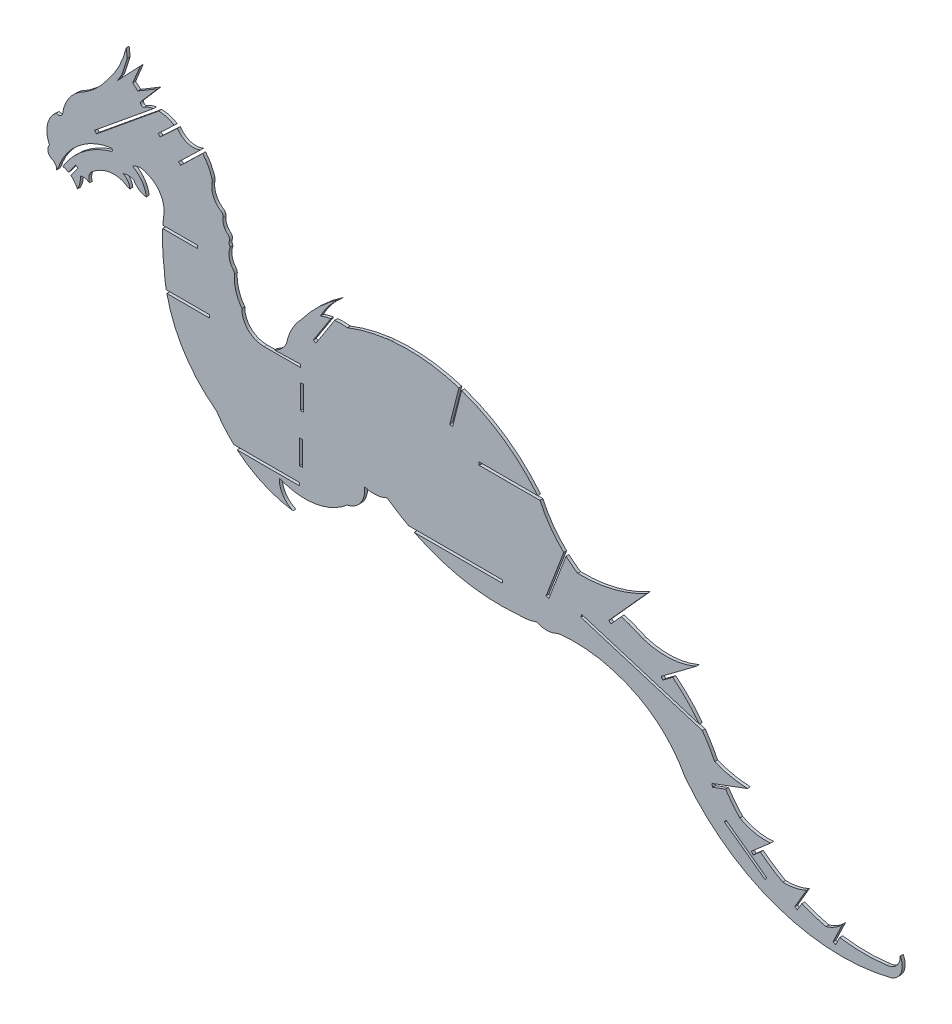
from build123d import *

# Parameters (mm, degrees)
BOSS_EXTRUDE1_DEPTH = 1.524
SKETCH2_W           = 25.4
SKETCH2_H           = 1.524
SKETCH2_W_2         = 19.05
CUT_EXTRUDE1_DEPTH  = 2.54
SKETCH3_W           = 35.680254641
SKETCH3_H           = 1.524
SKETCH3_W_2         = 1.524
SKETCH3_H_2         = 12.7
CUT_EXTRUDE2_DEPTH  = 1.524
SKETCH4_W           = 50.8
SKETCH4_H           = 1.524
SKETCH4_W_2         = 35.052
CUT_EXTRUDE3_DEPTH  = 2.54
CUT_EXTRUDE5_DEPTH  = 1.524
CUT_EXTRUDE6_DEPTH  = 1.524
BOSS_EXTRUDE3_DEPTH = 1.524
CUT_EXTRUDE11_DEPTH = 1.524
BOSS_EXTRUDE4_DEPTH = 1.524
CUT_EXTRUDE12_DEPTH = 1.524


with BuildPart() as part:
    # Sketch1 → Boss-Extrude1 (new body)
    with BuildSketch(Plane.XY):
        with BuildLine():
            Line((85.912962029, 218.976322287), (74.364894782, 207.800178371))
            Line((74.364894782, 207.800178371), (73.305043391, 208.895299839))
            Line((73.305043391, 208.895299839), (84.853110639, 220.071443755))
            ThreePointArc((84.853110639, 220.071443755), (78.049012426, 219.65544272), (72.670585697, 223.843680447))
            Line((72.670585697, 223.843680447), (63.510094231, 215.259742184))
            Line((63.510094231, 215.259742184), (62.468027874, 216.371800504))
            Line((62.468027874, 216.371800504), (70.942382834, 224.312787084))
            ThreePointArc((70.942382834, 224.312787084), (67.054478394, 226.098413751), (62.823075062, 226.730465466))
            Line((62.823075062, 226.730465466), (30.142398076, 199.999148642))
            Line((30.142398076, 199.999148642), (29.177504103, 201.1787908))
            Line((29.177504103, 201.1787908), (60.150273669, 226.513116541))
            ThreePointArc((60.150273669, 226.513116541), (57.805138379, 225.916638037), (55.584300985, 224.955738767))
            ThreePointArc((55.584300985, 224.955738767), (53.828520501, 224.627614987), (53.500396721, 226.383395471))
            Line((53.500396721, 226.383395471), (62.33783624, 236.627383356))
            Line((62.33783624, 236.627383356), (51.851124916, 230.366051046))
            Line((51.851124916, 230.366051046), (49.151424696, 232.695069558))
            Line((49.151424696, 232.695069558), (53.185497864, 242.40707472))
            Line((53.185497864, 242.40707472), (41.025224337, 229.643589626))
            Line((41.025224337, 229.643589626), (43.433429072, 233.496717201))
            Line((43.433429072, 233.496717201), (46.263069635, 242.40707472))
            Line((46.263069635, 242.40707472), (45.781428688, 247.042868834))
            ThreePointArc((45.781428688, 247.042868834), (41.995971337, 236.721956315), (35.94896473, 227.541290016))
            ThreePointArc((35.94896473, 227.541290016), (29.09512804, 219.879503048), (20.624117927, 214.055411308))
            ThreePointArc((20.624117927, 214.055411308), (15.224338721, 208.293396913), (12.411195321, 200.914735139))
            ThreePointArc((12.411195321, 200.914735139), (11.297888366, 198.952099018), (9.042009257, 198.90308507))
            ThreePointArc((9.042009257, 198.90308507), (4.33814825, 191.400740697), (5.45510478, 182.616442913))
            ThreePointArc((5.45510478, 182.616442913), (4.699658099, 179.178862984), (7.076072101, 176.582651909))
            ThreePointArc((7.076072101, 176.582651909), (8.681928736, 175.178852582), (9.155919385, 173.099246623))
            ThreePointArc((9.155919385, 173.099246623), (10.148365214, 174.754528749), (10.767132823, 176.582651909))
            ThreePointArc((10.767132823, 176.582651909), (21.457350988, 190.479061772), (37.540384678, 197.459534453))
            ThreePointArc((37.540384678, 197.459534453), (38.399050845, 197.023742181), (38.253676936, 196.07185515))
            ThreePointArc((38.253676936, 196.07185515), (23.454281696, 188.664818748), (12.411195666, 176.338564706))
            ThreePointArc((12.411195666, 176.338564706), (13.946155462, 175.867866548), (15.395234081, 175.17661443))
            Line((15.395234081, 175.17661443), (19.193185011, 180.368170906))
            Line((19.193185011, 180.368170906), (20.423183782, 179.468349244))
            Line((20.423183782, 179.468349244), (16.663613942, 174.329257269))
            ThreePointArc((16.663613942, 174.329257269), (18.661000235, 172.314724822), (20.070332405, 169.852677743))
            ThreePointArc((20.070332405, 169.852677743), (21.365371433, 173.099246623), (21.653855738, 176.582651909))
            ThreePointArc((21.653855738, 176.582651909), (24.130479455, 176.813374901), (26.404425737, 175.805373687))
            ThreePointArc((26.404425737, 175.805373687), (26.140099905, 178.575641373), (27.29048389, 181.109584523))
            ThreePointArc((27.29048389, 181.109584523), (31.315657742, 184.02733751), (35.94896473, 185.82949549))
            ThreePointArc((35.94896473, 185.82949549), (40.296382795, 186.180486334), (44.528814972, 185.127036633))
            ThreePointArc((44.528814972, 185.127036633), (46.050081316, 184.293182888), (47.664652975, 183.658579301))
            ThreePointArc((47.664652975, 183.658579301), (46.617864327, 186.759437448), (44.132482548, 188.888748401))
            ThreePointArc((44.132482548, 188.888748401), (46.927378665, 189.401991738), (49.720127416, 188.877189446))
            ThreePointArc((49.720127416, 188.877189446), (52.430877495, 185.78899139), (56.264556266, 184.309788796))
            ThreePointArc((56.264556266, 184.309788796), (54.005832171, 190.404410257), (49.151424692, 194.726559411))
            ThreePointArc((49.151424692, 194.726559411), (52.622637143, 196.071887584), (56.271469501, 195.333479703))
            ThreePointArc((56.271469501, 195.333479703), (63.140202409, 190.374955709), (65.667275166, 182.289143737))
            ThreePointArc((65.667275166, 182.289143737), (65.660634708, 182.146473197), (65.645985511, 182.004401456))
            ThreePointArc((65.645985511, 182.004401456), (65.308649849, 179.106572547), (65.05826469, 176.199939614))
            ThreePointArc((65.05826469, 176.199939614), (64.817716477, 170.23013431), (64.943690841, 164.25681285))
            ThreePointArc((64.943690841, 164.25681285), (65.248674161, 160.096824282), (65.731510792, 155.953710901))
            ThreePointArc((65.731510792, 155.953710901), (67.203599451, 145.391751604), (70.313958783, 135.191374453))
            ThreePointArc((70.313958783, 135.191374453), (71.821055501, 131.656935237), (73.525998925, 128.213569296))
            ThreePointArc((73.525998925, 128.213569296), (75.812647336, 124.2377173), (78.362926142, 120.425600032))
            ThreePointArc((78.362926142, 120.425600032), (82.189502592, 115.585453313), (86.440342726, 111.113310007))
            ThreePointArc((86.440342726, 111.113310007), (89.706771856, 108.17353201), (93.156824508, 105.451585897))
            ThreePointArc((93.156824508, 105.451585897), (110.528802987, 88.41476958), (133.395125801, 80.097917564))
            ThreePointArc((133.395125801, 80.097917564), (128.017180612, 84.692098497), (126.161809959, 91.517521021))
            ThreePointArc((126.161809959, 91.517521021), (144.825398714, 89.083026927), (161.902871554, 96.996068574))
            ThreePointArc((161.902871554, 96.996068574), (162.581404673, 97.150550573), (163.249151491, 97.3464742))
            ThreePointArc((163.249151491, 97.3464742), (169.387880456, 102.206558666), (170.898468081, 109.889171461))
            ThreePointArc((170.898468081, 109.889171461), (176.948552887, 109.130034546), (182.834138314, 110.723677912))
            ThreePointArc((182.834138314, 110.723677912), (215.501976144, 95.153256417), (251.553345423, 92.002950555))
            ThreePointArc((251.553345423, 92.002950555), (256.5263716, 92.287511732), (261.361002985, 93.486804767))
            ThreePointArc((261.361002985, 93.486804767), (265.661731663, 92.408703764), (270.068903721, 92.893887626))
            ThreePointArc((270.068903721, 92.893887626), (271.340370106, 93.345191698), (272.556022414, 93.930419519))
            ThreePointArc((272.556022414, 93.930419519), (294.27155938, 93.339542333), (314.820447647, 86.292779066))
            ThreePointArc((314.820447647, 86.292779066), (328.900505636, 75.991617879), (339.316129191, 61.996020689))
            ThreePointArc((339.316129191, 61.996020689), (388.035667666, 27.098915876), (447.920780712, 24.824143603))
            ThreePointArc((447.920780712, 24.824143603), (452.972758024, 29.895353293), (452.453481655, 37.03468061))
            ThreePointArc((452.453481655, 37.03468061), (450.48843079, 31.782753677), (445.425652694, 29.371853565))
            ThreePointArc((445.425652694, 29.371853565), (398.363856878, 35.971380344), (361.481703529, 65.939248862))
            ThreePointArc((361.481703529, 65.939248862), (358.230212062, 70.862760514), (355.313625064, 75.99176471))
            ThreePointArc((355.313625064, 75.99176471), (331.13682687, 105.472605001), (296.078527974, 120.457704058))
            ThreePointArc((296.078527974, 120.457704058), (295.802256425, 120.519391998), (295.534564817, 120.611438582))
            ThreePointArc((295.534564817, 120.611438582), (291.740578327, 122.096977041), (287.907209287, 123.477715902))
            ThreePointArc((287.907209287, 123.477715902), (287.71041735, 123.554861551), (287.520721146, 123.648102463))
            ThreePointArc((287.520721146, 123.648102463), (273.213478114, 134.730431911), (263.136393827, 149.76265069))
            ThreePointArc((263.136393827, 149.76265069), (228.535543485, 176.616937868), (185.253442578, 183.327476244))
            Line((185.253442578, 183.327476244), (169.728576525, 168.087659552))
            Line((169.728576525, 168.087659552), (168.660976375, 169.175228363))
            Line((168.660976375, 169.175228363), (182.792290548, 183.047079939))
            ThreePointArc((182.792290548, 183.047079939), (172.181721047, 181.012984757), (161.902904246, 177.686176451))
            ThreePointArc((161.902904246, 177.686176451), (158.600549933, 177.91649897), (155.293596172, 177.766002118))
            Line((155.293596172, 177.766002118), (145.35756693, 162.352041201))
            Line((145.35756693, 162.352041201), (144.076634601, 163.177745973))
            Line((144.076634601, 163.177745973), (153.302149625, 177.489471969))
            ThreePointArc((153.302149625, 177.489471969), (150.516535783, 176.859034352), (147.807142579, 175.955549696))
            ThreePointArc((147.807142579, 175.955549696), (152.400105667, 182.90469922), (158.253046613, 188.831677481))
            ThreePointArc((158.253046613, 188.831677481), (147.165486742, 179.923609241), (137.713521339, 169.29590894))
            ThreePointArc((137.713521339, 169.29590894), (132.746974171, 162.463425903), (129.978417774, 154.483168345))
            ThreePointArc((129.978417774, 154.483168345), (123.225134742, 148.241786274), (114.033790221, 147.957413737))
            ThreePointArc((114.033790221, 147.957413737), (108.511816279, 152.106071011), (106.529948644, 158.722395827))
            ThreePointArc((106.529948644, 158.722395827), (103.348649188, 165.164931098), (102.563630061, 172.30710667))
            ThreePointArc((102.563630061, 172.30710667), (102.437713886, 173.278490517), (101.953591078, 174.129998925))
            ThreePointArc((101.953591078, 174.129998925), (99.859339664, 178.593240513), (100.380158002, 183.495807466))
            ThreePointArc((100.380158002, 183.495807466), (99.850597988, 184.746376921), (99.941789819, 186.101383128))
            ThreePointArc((99.941789819, 186.101383128), (99.945959825, 187.594296625), (99.110677409, 188.831677481))
            ThreePointArc((99.110677409, 188.831677481), (97.032516131, 191.658219228), (96.620127494, 195.142186529))
            ThreePointArc((96.620127494, 195.142186529), (96.410256248, 196.563926462), (95.462412123, 197.644195824))
            ThreePointArc((95.462412123, 197.644195824), (91.490191499, 202.332428186), (90.909159352, 208.449654765))
            ThreePointArc((90.909159352, 208.449654765), (90.963307308, 209.060156595), (90.869641743, 209.66585557))
            ThreePointArc((90.869641743, 209.66585557), (88.893307621, 214.58834531), (85.912962029, 218.976322287))
        make_face()
    extrude(amount=BOSS_EXTRUDE1_DEPTH)

    # Sketch2 → Cut-Extrude1 (cut)
    with BuildSketch(Plane.XY.offset(1.524)):
        with Locations((76.728418917, 146.642575386)):
            Rectangle(SKETCH2_W, SKETCH2_H)
        with Locations((73.553418917, 175.110998199)):
            Rectangle(SKETCH2_W_2, SKETCH2_H)
    extrude(amount=-CUT_EXTRUDE1_DEPTH, mode=Mode.SUBTRACT)

    # Sketch3 → Cut-Extrude2 (cut)
    with BuildSketch(Plane.XY.offset(1.524)):
        Polygon((118.248884428, 147.262863837), (137.298884428, 147.262863837), (137.298884428, 148.786863837), (118.248884428, 148.241786274), align=None)
        with Locations((119.065368354, 93.929486967)):
            Rectangle(SKETCH3_W, SKETCH3_H)
        with Locations((138.060884428, 134.043246422)):
            Rectangle(SKETCH3_W_2, SKETCH3_H_2)
        with Locations((137.667495674, 108.668629124)):
            Rectangle(SKETCH3_W_2, SKETCH3_H_2)
    extrude(amount=-CUT_EXTRUDE2_DEPTH, mode=Mode.SUBTRACT)

    # Sketch4 → Cut-Extrude3 (cut)
    with BuildSketch(Plane.XY.offset(1.524)):
        with Locations((217.951019941, 102.920744618)):
            Rectangle(SKETCH4_W, SKETCH4_H)
        with Locations((248.728186388, 150.497981852)):
            Rectangle(SKETCH4_W_2, SKETCH4_H)
    extrude(amount=-CUT_EXTRUDE3_DEPTH, mode=Mode.SUBTRACT)

    # Sketch5 → Cut-Extrude5 (cut)
    with BuildSketch(Plane.XY.offset(1.524)):
        Polygon((267.807092877, 107.381254896), (279.061723188, 136.998703084), (277.637113011, 137.540054951), (266.3824827, 107.922606763), align=None)
    extrude(amount=-CUT_EXTRUDE5_DEPTH, mode=Mode.SUBTRACT)

    # Sketch6 → Cut-Extrude6 (cut)
    with BuildSketch(Plane.XY.offset(1.524)):
        Polygon((284.642268521, 107.315466389), (351.690377928, 86.685278879), (352.138564761, 88.141886089), (285.090455354, 108.772073599), align=None)
        Polygon((360.08280295, 51.82163244), (381.410964254, 36.333324827), (382.306464812, 37.566473136), (360.978303508, 53.054780749), align=None)
    extrude(amount=-CUT_EXTRUDE6_DEPTH, mode=Mode.SUBTRACT)

    # Sketch7 → Boss-Extrude3 (add)
    with BuildSketch(Plane.XY.offset(1.524)):
        with BuildLine():
            Line((319.492623383, 135.605984619), (302.318496725, 116.540894281))
            ThreePointArc((302.318496725, 116.540894281), (291.299212918, 118.92345081), (282.907641661, 126.452243747))
            ThreePointArc((282.907641661, 126.452243747), (301.813363995, 128.578196843), (319.492623383, 135.605984619))
        make_face()
        with BuildLine():
            Line((345.27800645, 115.292669365), (329.318902069, 103.331567978))
            ThreePointArc((329.318902069, 103.331567978), (323.702245585, 109.009219227), (317.322016795, 113.81288807))
            ThreePointArc((317.322016795, 113.81288807), (331.435762813, 111.988170752), (345.27800645, 115.292669365))
        make_face()
        with BuildLine():
            Line((372.162784884, 73.11282114), (357.551927932, 67.621343324))
            ThreePointArc((357.551927932, 67.621343324), (354.72202161, 72.334177506), (352.968722233, 77.544275116))
            ThreePointArc((352.968722233, 77.544275116), (362.359608449, 74.435666883), (372.162784884, 73.11282114))
        make_face()
        with BuildLine():
            Line((384.327609054, 54.38668931), (376.050543611, 47.152723382))
            ThreePointArc((376.050543611, 47.152723382), (370.99557625, 51.604779276), (368.107483636, 57.690205945))
            ThreePointArc((368.107483636, 57.690205945), (375.971332026, 54.82954585), (384.327609054, 54.38668931))
        make_face()
        with BuildLine():
            Line((403.184390329, 42.298192313), (398.841483719, 34.856925327))
            ThreePointArc((398.841483719, 34.856925327), (393.271190569, 36.173378438), (388.895405056, 39.863055349))
            ThreePointArc((388.895405056, 39.863055349), (396.198488731, 40.150037562), (403.184390329, 42.298192313))
        make_face()
        with BuildLine():
            Line((422.183880159, 36.405245227), (418.546341262, 28.785168076))
            ThreePointArc((418.546341262, 28.785168076), (414.808004466, 28.765424076), (411.48384369, 30.475835416))
            ThreePointArc((411.48384369, 30.475835416), (417.32984678, 32.545500814), (422.183880159, 36.405245227))
        make_face()
    extrude(amount=-BOSS_EXTRUDE3_DEPTH)

    # Sketch11 → Cut-Extrude11 (cut)
    with BuildSketch(Plane.XY.offset(1.524)):
        Polygon((300.437266577, 112.175522619), (306.285750423, 118.66795598), (304.643653929, 119.122063794), (299.3049455, 113.195534864), align=None)
        Polygon((327.71386955, 100.224092249), (333.670967848, 104.688845096), (332.425014359, 105.659550998), (326.799871937, 101.443593936), align=None)
        Polygon((353.937387239, 64.552723096), (363.762156332, 68.245353973), (362.992582539, 69.666208603), (353.374204884, 66.051149768), align=None)
        Polygon((375.262528664, 44.443965004), (380.65246391, 49.150680773), (379.650046957, 50.298606998), (374.260111712, 45.591891229), align=None)
        Polygon((398.353293266, 30.996987816), (401.682706497, 36.701704723), (400.366474352, 37.469890208), (397.03706112, 31.765173301), align=None)
        Polygon((418.524481738, 25.201734798), (421.290918068, 30.996987816), (419.821895067, 31.457254528), (417.149148622, 25.85826722), align=None)
    extrude(amount=-CUT_EXTRUDE11_DEPTH, mode=Mode.SUBTRACT)

    # Sketch12 → Boss-Extrude4 (add)
    with BuildSketch(Plane.XY.offset(1.524)):
        with BuildLine():
            Line((182.792290548, 183.047079939), (168.660976375, 169.175228363))
            Line((168.660976375, 169.175228363), (169.728576525, 168.087659552))
            Line((169.728576525, 168.087659552), (185.253442578, 183.327476244))
            ThreePointArc((185.253442578, 183.327476244), (184.016606712, 183.242223342), (182.792290548, 183.047079939))
        make_face()
    extrude(amount=-BOSS_EXTRUDE4_DEPTH)

    # Sketch13 → Cut-Extrude12 (cut)
    with BuildSketch(Plane(origin=(0, 0, 0), x_dir=(-1, 0, 0), z_dir=(0, 0, -1))):
        Polygon((-215.747925209, 160.630266395), (-221.276506883, 182.534992727), (-222.754168584, 182.162042466), (-217.22558691, 160.257316134), align=None)
    extrude(amount=-CUT_EXTRUDE12_DEPTH, mode=Mode.SUBTRACT)


solid = part.part
